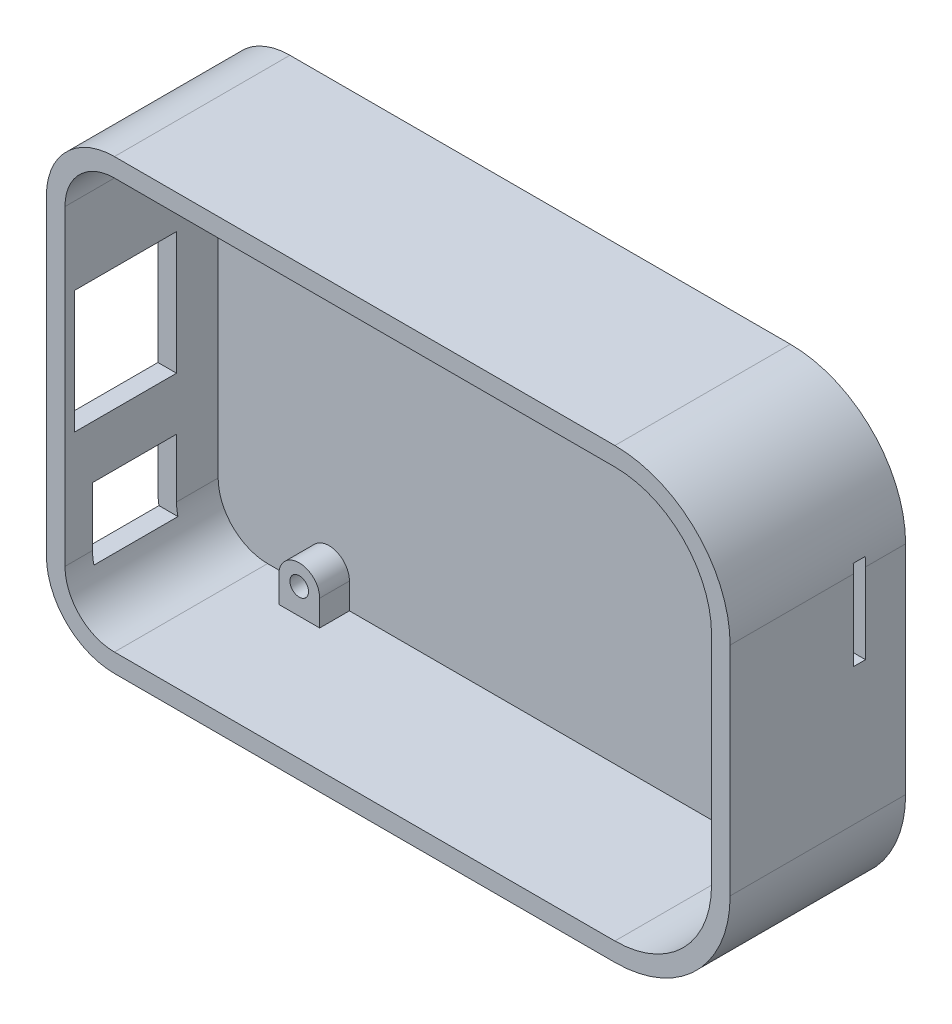
from build123d import *

# Parameters (mm, degrees)
SKETCH5_R                    = 1.25
BOTTOM_FRAME_DEPTH           = 4
PCB_DEPTH                    = 1.6
SKETCH7_W                    = 2.5
SKETCH7_H                    = 7.1
UPPER_FRAME_DEPTH            = 15
BOTTOM_DEPTH                 = 3
SKETCH9_W                    = 2.5
SKETCH9_H                    = 16.5
NETWORK_CONNECTOR_BOSS_DEPTH = 1.3
BOSS_EXTRUDE8_DEPTH          = 3.7
MINI_USB_REACH               = 93.96
SKETCH11_W                   = 3.9
SKETCH11_H                   = 7.7
CUT_EXTRUDE3_REACH           = 93.96
SKETCH12_W                   = 1.61
SKETCH12_H                   = 12


with BuildPart() as part:
    # Sketch5 → Bottom frame (new body)
    with BuildSketch(Plane.XY):
        with BuildLine():
            Line((73.66, 57.41), (6.35, 57.41))
            ThreePointArc((6.35, 57.41), (-0.120027048, 54.730027048), (-2.8, 48.26))
            Line((-2.8, 48.26), (-2.8, 6.35))
            ThreePointArc((-2.8, 6.35), (-0.120027048, -0.120027048), (6.35, -2.8))
            Line((6.35, -2.8), (73.66, -2.8))
            ThreePointArc((73.66, -2.8), (84.620155108, 1.739844892), (89.16, 12.7))
            Line((89.16, 12.7), (89.16, 41.91))
            ThreePointArc((89.16, 41.91), (84.620155108, 52.870155108), (73.66, 57.41))
        make_face()
        with Locations((14.605, 51.435)):
            Circle(SKETCH5_R, mode=Mode.SUBTRACT)
        with Locations((80.645, 48.26)):
            Circle(SKETCH5_R, mode=Mode.SUBTRACT)
        with Locations((80.645, 6.35)):
            Circle(SKETCH5_R, mode=Mode.SUBTRACT)
        with Locations((14.605, 3.175)):
            Circle(SKETCH5_R, mode=Mode.SUBTRACT)
        with BuildLine():
            Line((73.66, 54.91), (17.355, 54.91))
            Line((17.355, 54.91), (17.355, 51.435))
            ThreePointArc((17.355, 51.435), (14.605, 48.685), (11.855, 51.435))
            Line((11.855, 51.435), (11.855, 54.91))
            Line((11.855, 54.91), (6.35, 54.91))
            ThreePointArc((6.35, 54.91), (1.647739905, 52.962260095), (-0.3, 48.26))
            Line((-0.3, 48.26), (-0.3, 6.35))
            ThreePointArc((-0.3, 6.35), (1.647739905, 1.647739905), (6.35, -0.3))
            Line((6.35, -0.3), (11.855, -0.3))
            Line((11.855, -0.3), (11.855, 3.175))
            ThreePointArc((11.855, 3.175), (14.605, 5.925), (17.355, 3.175))
            Line((17.355, 3.175), (17.355, -0.3))
            Line((17.355, -0.3), (73.66, -0.3))
            ThreePointArc((73.66, -0.3), (75.806982263, -0.121484593), (77.895, 0.409158898))
            Line((77.895, 0.409158898), (77.895, 6.35))
            ThreePointArc((77.895, 6.35), (78.700456352, 8.294543648), (80.645, 9.1))
            Line((80.645, 9.1), (86.151597176, 9.1))
            ThreePointArc((86.151597176, 9.1), (86.532271814, 10.882139071), (86.66, 12.7))
            Line((86.66, 12.7), (86.66, 41.91))
            ThreePointArc((86.66, 41.91), (86.532271814, 43.727860929), (86.151597176, 45.51))
            Line((86.151597176, 45.51), (80.645, 45.51))
            ThreePointArc((80.645, 45.51), (78.700456352, 46.315456352), (77.895, 48.26))
            Line((77.895, 48.26), (77.895, 54.200841102))
            ThreePointArc((77.895, 54.200841102), (75.806982263, 54.731484593), (73.66, 54.91))
        make_face(mode=Mode.SUBTRACT)
    extrude(amount=BOTTOM_FRAME_DEPTH)

    # Sketch6 → PCB (add)
    with BuildSketch(Plane.XY.offset(4)):
        with BuildLine():
            Line((73.66, 57.41), (6.35, 57.41))
            ThreePointArc((6.35, 57.41), (-0.120027048, 54.730027048), (-2.8, 48.26))
            Line((-2.8, 48.26), (-2.8, 6.35))
            ThreePointArc((-2.8, 6.35), (-0.120027048, -0.120027048), (6.35, -2.8))
            Line((6.35, -2.8), (73.66, -2.8))
            ThreePointArc((73.66, -2.8), (84.620155108, 1.739844892), (89.16, 12.7))
            Line((89.16, 12.7), (89.16, 41.91))
            ThreePointArc((89.16, 41.91), (84.620155108, 52.870155108), (73.66, 57.41))
        make_face()
        with BuildLine():
            Line((-0.3, 48.26), (-0.3, 6.35))
            ThreePointArc((-0.3, 6.35), (1.647739905, 1.647739905), (6.35, -0.3))
            Line((6.35, -0.3), (73.66, -0.3))
            ThreePointArc((73.66, -0.3), (82.852388155, 3.507611845), (86.66, 12.7))
            Line((86.66, 12.7), (86.66, 41.91))
            ThreePointArc((86.66, 41.91), (82.852388155, 51.102388155), (73.66, 54.91))
            Line((73.66, 54.91), (6.35, 54.91))
            ThreePointArc((6.35, 54.91), (1.647739905, 52.962260095), (-0.3, 48.26))
        make_face(mode=Mode.SUBTRACT)
    extrude(amount=PCB_DEPTH)

    # Sketch7 → upper frame (add)
    with BuildSketch(Plane.XY.offset(5.6)):
        with BuildLine():
            Line((6.35, 54.91), (73.66, 54.91))
            ThreePointArc((73.66, 54.91), (82.852388155, 51.102388155), (86.66, 41.91))
            Line((86.66, 41.91), (86.66, 12.7))
            ThreePointArc((86.66, 12.7), (82.852388155, 3.507611845), (73.66, -0.3))
            Line((73.66, -0.3), (6.35, -0.3))
            ThreePointArc((6.35, -0.3), (2.252287223, 1.112514916), (-0.104649487, 4.75))
            Line((-0.104649487, 4.75), (-2.659023254, 4.75))
            ThreePointArc((-2.659023254, 4.75), (0.472819554, -0.662934479), (6.35, -2.8))
            Line((6.35, -2.8), (73.66, -2.8))
            ThreePointArc((73.66, -2.8), (84.620155108, 1.739844892), (89.16, 12.7))
            Line((89.16, 12.7), (89.16, 41.91))
            ThreePointArc((89.16, 41.91), (84.620155108, 52.870155108), (73.66, 57.41))
            Line((73.66, 57.41), (6.35, 57.41))
            ThreePointArc((6.35, 57.41), (-0.120027048, 54.730027048), (-2.8, 48.26))
            Line((-2.8, 48.26), (-2.8, 37.85))
            Line((-2.8, 37.85), (-0.3, 37.85))
            Line((-0.3, 37.85), (-0.3, 48.26))
            ThreePointArc((-0.3, 48.26), (1.647739905, 52.962260095), (6.35, 54.91))
        make_face()
        with Locations((-1.55, 17.8)):
            Rectangle(SKETCH7_W, SKETCH7_H)
    extrude(amount=UPPER_FRAME_DEPTH)

    # Sketch8 → bottom (add)
    with BuildSketch(Plane(origin=(0, 0, 0), x_dir=(-1, 0, 0), z_dir=(0, 0, -1))):
        with BuildLine():
            Line((-89.16, 41.91), (-89.16, 12.7))
            ThreePointArc((-89.16, 12.7), (-84.620155108, 1.739844892), (-73.66, -2.8))
            Line((-73.66, -2.8), (-6.35, -2.8))
            ThreePointArc((-6.35, -2.8), (0.120027048, -0.120027048), (2.8, 6.35))
            Line((2.8, 6.35), (2.8, 48.26))
            ThreePointArc((2.8, 48.26), (0.120027048, 54.730027048), (-6.35, 57.41))
            Line((-6.35, 57.41), (-73.66, 57.41))
            ThreePointArc((-73.66, 57.41), (-84.620155108, 52.870155108), (-89.16, 41.91))
        make_face()
    extrude(amount=BOTTOM_DEPTH)

    # Sketch9 → network connector boss (add)
    with BuildSketch(Plane.XY.offset(20.6)):
        with Locations((-1.55, 29.6)):
            Rectangle(SKETCH9_W, SKETCH9_H)
    extrude(amount=-NETWORK_CONNECTOR_BOSS_DEPTH)

    # Sketch10 → Boss-Extrude8 (add)
    with BuildSketch(Plane.XY.offset(20.6)):
        with BuildLine():
            Line((-0.3, 14.25), (-2.8, 14.25))
            Line((-2.8, 14.25), (-2.8, 6.35))
            ThreePointArc((-2.8, 6.35), (-2.764687674, 5.546900622), (-2.659023254, 4.75))
            Line((-2.659023254, 4.75), (-0.104649487, 4.75))
            ThreePointArc((-0.104649487, 4.75), (-0.250981711, 5.544059273), (-0.3, 6.35))
            Line((-0.3, 6.35), (-0.3, 14.25))
        make_face()
    extrude(amount=-BOSS_EXTRUDE8_DEPTH)

    # Sketch11 → mini-USB (cut, up to next)
    with BuildSketch(Plane.ZY.offset(2.8), mode=Mode.PRIVATE) as mini_usb_sk1:
        with Locations((2.05, 44.21)):
            Rectangle(SKETCH11_W, SKETCH11_H)
    mini_usb_tool1 = extrude(mini_usb_sk1.sketch, amount=-MINI_USB_REACH, mode=Mode.PRIVATE) & part.part
    add(mini_usb_tool1.solids().sort_by_distance((-2.8, 44.21, 2.05))[0], mode=Mode.SUBTRACT)

    # Sketch12 → Cut-Extrude3 (cut, up to next)
    with BuildSketch(Plane(origin=(89.16, 0, 0), x_dir=(0, 0, -1), z_dir=(1, 0, 0)), mode=Mode.PRIVATE) as cut_extrude3_sk1:
        with Locations((-3.195, 37.11)):
            Rectangle(SKETCH12_W, SKETCH12_H)
    cut_extrude3_tool1 = extrude(cut_extrude3_sk1.sketch, amount=-CUT_EXTRUDE3_REACH, mode=Mode.PRIVATE) & part.part
    add(cut_extrude3_tool1.solids().sort_by_distance((89.16, 37.11, 3.195))[0], mode=Mode.SUBTRACT)


solid = part.part
